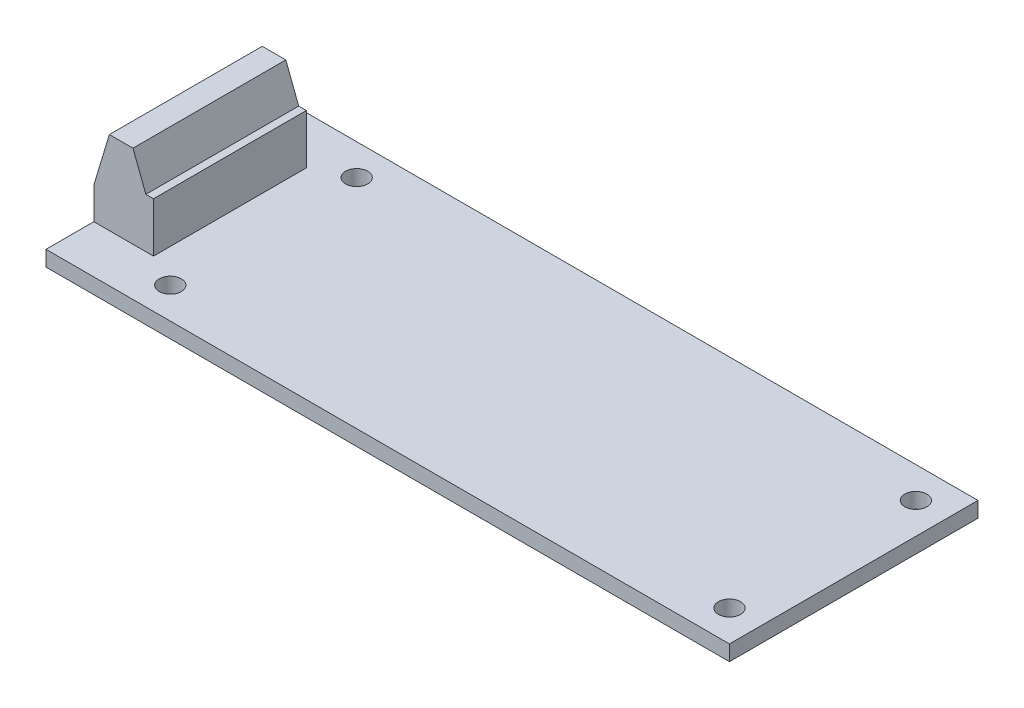
from build123d import *

# Parameters (mm, degrees)
SKETCH2_W                 = 69.85
SKETCH2_H                 = 25.4
BOSS_EXTRUDE1_DEPTH       = 1.5748
TAP_DRILL_FOR_4_40_TAP1_D = 2.2606
BOSS_EXTRUDE2_DEPTH       = 7.8105


with BuildPart() as part:
    # Sketch2 → Boss-Extrude1 (new body)
    with BuildSketch(Plane(origin=(0, 0, 0), x_dir=(1, 0, 0), z_dir=(0, 1, 0))):
        with Locations((34.925, 12.7)):
            Rectangle(SKETCH2_W, SKETCH2_H)
    extrude(amount=BOSS_EXTRUDE1_DEPTH)

    # Tap Drill for #4-40 Tap1 (through all)
    with Locations(Plane(origin=(9.525, 1.5748, -22.225), x_dir=(0, 0, 1), z_dir=(0, 1, 0))):
        with Locations((0, 0), (19.05, 0), (19.05, 57.15), (0, 57.15)):
            Hole(TAP_DRILL_FOR_4_40_TAP1_D / 2)

    # Sketch4 → Boss-Extrude2 (add, symmetric)
    with BuildSketch(Plane.XY.offset(-12.7)):
        Polygon((0, 1.5748), (0, 4.817906029), (1.588475565, 10.0838), (3.999524435, 10.0838), (5.314976691, 6.6548), (6.096, 6.6548), (6.096, 1.5748), align=None)
    extrude(amount=BOSS_EXTRUDE2_DEPTH, both=True)


solid = part.part
